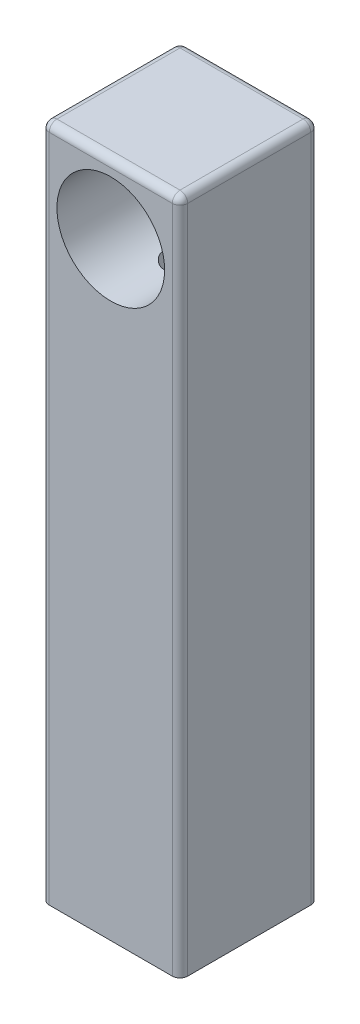
from build123d import *

# Parameters (mm, degrees)
BOSS_EXTRUDE1_DEPTH = 279.4
SKETCH1_4_R         = 4.96062
CUT_EXTRUDE1_DEPTH  = 25.4
SKETCH1_5_R         = 6.35
CUT_EXTRUDE2_DEPTH  = 250.825
FILLET1_R           = 3.175
SKETCH4_R           = 22.225
CUT_EXTRUDE3_DEPTH  = 44.45


with BuildPart() as part:
    # Sketch1 → Boss-Extrude1 (new body)
    with BuildSketch(Plane(origin=(0, 0, 0), x_dir=(1, 0, 0), z_dir=(0, 1, 0))):
        with BuildLine():
            Line((-24.257, 27.504571429), (26.543, 27.504571429))
            ThreePointArc((26.543, 27.504571429), (28.78806403, 26.574635459), (29.718, 24.329571429))
            Line((29.718, 24.329571429), (29.718, -26.470428571))
            ThreePointArc((29.718, -26.470428571), (28.78806403, -28.715492602), (26.543, -29.645428571))
            Line((26.543, -29.645428571), (-24.257, -29.645428571))
            ThreePointArc((-24.257, -29.645428571), (-26.50206403, -28.715492602), (-27.432, -26.470428571))
            Line((-27.432, -26.470428571), (-27.432, 24.329571429))
            ThreePointArc((-27.432, 24.329571429), (-26.50206403, 26.574635459), (-24.257, 27.504571429))
        make_face()
    extrude(amount=BOSS_EXTRUDE1_DEPTH)

    # Sketch1_4 → Cut-Extrude1 (cut)
    with BuildSketch(Plane(origin=(0, 0, 0), x_dir=(1, 0, 0), z_dir=(0, 1, 0))):
        with Locations((-13.1445, 13.217071429)):
            Circle(SKETCH1_4_R)
        with Locations((15.4305, 13.217071429)):
            Circle(SKETCH1_4_R)
        with Locations((15.4305, -15.357928571)):
            Circle(SKETCH1_4_R)
        with Locations((-13.1445, -15.357928571)):
            Circle(SKETCH1_4_R)
    extrude(amount=CUT_EXTRUDE1_DEPTH, mode=Mode.SUBTRACT)

    # Sketch1_5 → Cut-Extrude2 (cut)
    with BuildSketch(Plane(origin=(0, 0, 0), x_dir=(1, 0, 0), z_dir=(0, 1, 0))):
        with Locations((1.143, -1.070428571)):
            Circle(SKETCH1_5_R)
    extrude(amount=CUT_EXTRUDE2_DEPTH, mode=Mode.SUBTRACT)

    # Fillet1
    fillet1_edges = [part.edges().sort_by_distance(p)[0] for p in [
        (28.78806403, 279.4, -26.574635459),
        (1.143, 279.4, -27.504571429),
        (-26.50206403, 279.4, -26.574635459),
        (-27.432, 279.4, 1.070428571),
        (-26.50206403, 279.4, 28.715492602),
        (1.143, 279.4, 29.645428571),
        (28.78806403, 279.4, 28.715492602),
        (29.718, 279.4, 1.070428571),
    ]]
    fillet(fillet1_edges, radius=FILLET1_R)

    # Sketch4 → Cut-Extrude3 (cut)
    with BuildSketch(Plane.XY.offset(29.645428571)):
        with Locations((1.143, 250.825)):
            Circle(SKETCH4_R)
    extrude(amount=-CUT_EXTRUDE3_DEPTH, mode=Mode.SUBTRACT)


solid = part.part
